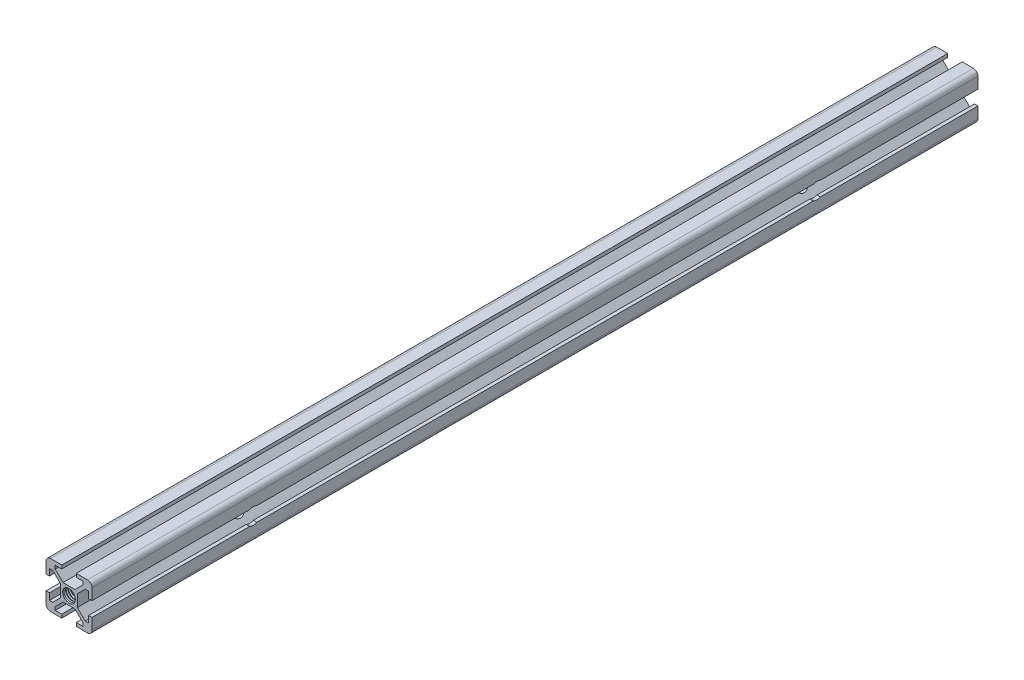
from build123d import *

# Parameters (mm, degrees)
SKETCH1_R           = 2.75
BOSS_EXTRUDE1_DEPTH = 385
CUT_SWEEP2_PITCH    = 1
CUT_SWEEP2_HEIGHT   = 18.5
CUT_SWEEP2_RADIUS   = 2.15
SKETCH4_R           = 3.5
CUT_EXTRUDE1_DEPTH  = 21


with BuildPart() as part:
    # Sketch1 → Boss-Extrude1 (new body)
    with BuildSketch(Plane.XY):
        with BuildLine():
            Line((-2.599339828, -3.66), (2.599339828, -3.66))
            Line((2.599339828, -3.66), (5.995, -7.055660172))
            Line((5.995, -7.055660172), (5.995, -8.5))
            Line((5.995, -8.5), (3.15, -8.5))
            Line((3.15, -8.5), (3.15, -10))
            Line((3.15, -10), (8, -10))
            ThreePointArc((8, -10), (9.414213562, -9.414213562), (10, -8))
            Line((10, -8), (10, -3.15))
            Line((10, -3.15), (8.5, -3.15))
            Line((8.5, -3.15), (8.5, -5.995))
            Line((8.5, -5.995), (7.055660172, -5.995))
            Line((7.055660172, -5.995), (3.66, -2.599339828))
            Line((3.66, -2.599339828), (3.66, 2.599339828))
            Line((3.66, 2.599339828), (7.055660172, 5.995))
            Line((7.055660172, 5.995), (8.5, 5.995))
            Line((8.5, 5.995), (8.5, 3.15))
            Line((8.5, 3.15), (10, 3.15))
            Line((10, 3.15), (10, 8))
            ThreePointArc((10, 8), (9.414213562, 9.414213562), (8, 10))
            Line((8, 10), (3.15, 10))
            Line((3.15, 10), (3.15, 8.5))
            Line((3.15, 8.5), (5.995, 8.5))
            Line((5.995, 8.5), (5.995, 7.055660172))
            Line((5.995, 7.055660172), (2.599339828, 3.66))
            Line((2.599339828, 3.66), (-2.599339828, 3.66))
            Line((-2.599339828, 3.66), (-5.995, 7.055660172))
            Line((-5.995, 7.055660172), (-5.995, 8.5))
            Line((-5.995, 8.5), (-3.15, 8.5))
            Line((-3.15, 8.5), (-3.15, 10))
            Line((-3.15, 10), (-8, 10))
            ThreePointArc((-8, 10), (-9.414213562, 9.414213562), (-10, 8))
            Line((-10, 8), (-10, 3.15))
            Line((-10, 3.15), (-8.5, 3.15))
            Line((-8.5, 3.15), (-8.5, 5.995))
            Line((-8.5, 5.995), (-7.055660172, 5.995))
            Line((-7.055660172, 5.995), (-3.66, 2.599339828))
            Line((-3.66, 2.599339828), (-3.66, -2.599339828))
            Line((-3.66, -2.599339828), (-7.055660172, -5.995))
            Line((-7.055660172, -5.995), (-8.5, -5.995))
            Line((-8.5, -5.995), (-8.5, -3.15))
            Line((-8.5, -3.15), (-10, -3.15))
            Line((-10, -3.15), (-10, -8))
            ThreePointArc((-10, -8), (-9.414213562, -9.414213562), (-8, -10))
            Line((-8, -10), (-3.15, -10))
            Line((-3.15, -10), (-3.15, -8.5))
            Line((-3.15, -8.5), (-5.995, -8.5))
            Line((-5.995, -8.5), (-5.995, -7.055660172))
            Line((-5.995, -7.055660172), (-2.599339828, -3.66))
        make_face()
        Circle(SKETCH1_R, mode=Mode.SUBTRACT)
    extrude(amount=BOSS_EXTRUDE1_DEPTH)

    # Cut-Sweep2: sweep along a helix
    with BuildLine() as cut_sweep2_path:
        Helix(CUT_SWEEP2_PITCH, CUT_SWEEP2_HEIGHT, CUT_SWEEP2_RADIUS, center=(0, 0, 1), direction=(0, 0, 1))
    # Sketch3 → Cut-Sweep2 (sweep, cut)
    with BuildSketch(Plane(origin=(0, 0, 0), x_dir=(0, 0, -1), z_dir=(1, 0, 0))):
        Polygon((-0.65, 3.389519053), (-1.025, 2.74), (-0.275, 2.74), align=None)
    cut_sweep2 = sweep(path=cut_sweep2_path.line, is_frenet=True, mode=Mode.SUBTRACT)

    # Mirror1: Cut-Sweep2 across plane
    add(cut_sweep2.mirror(Plane(origin=(0, 0, 192.5), x_dir=(1, 0, 0), z_dir=(0, 0, -1))), mode=Mode.SUBTRACT)

    # Sketch4 → Cut-Extrude1 (cut, through all)
    with BuildSketch(Plane.ZY.offset(10)):
        with Locations((70.030773481, 0)):
            Circle(SKETCH4_R)
        with Locations((314.969226519, 0)):
            Circle(SKETCH4_R)
    extrude(amount=-CUT_EXTRUDE1_DEPTH, mode=Mode.SUBTRACT)


solid = part.part
